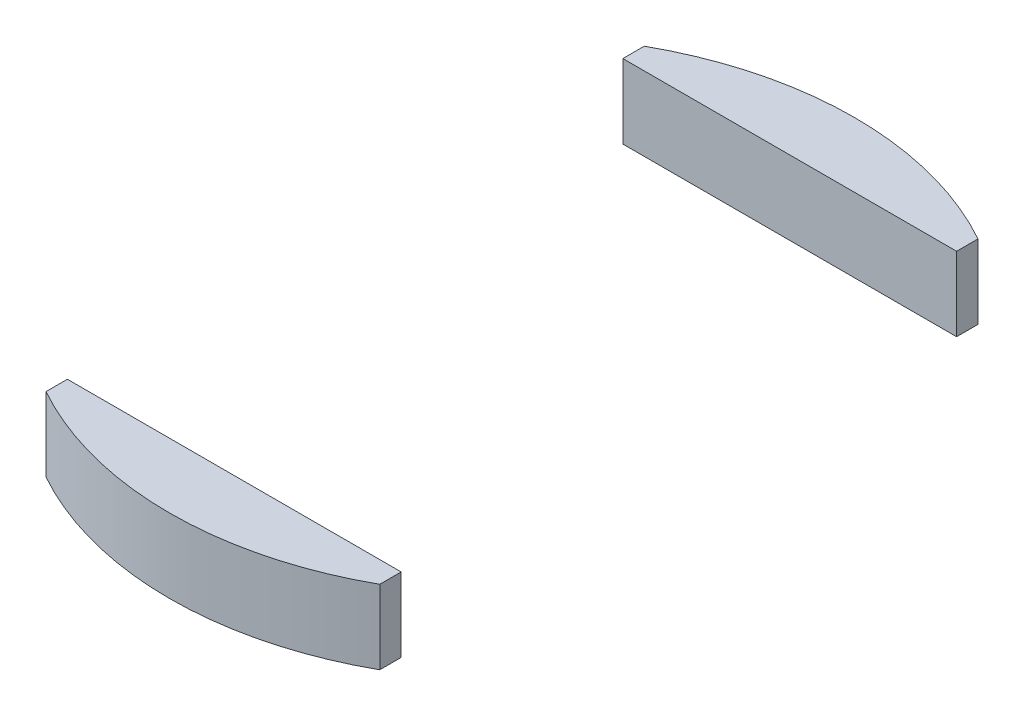
from build123d import *

# Parameters (mm, degrees)
BOSS_EXTRUDE1_DEPTH = 4


with BuildPart() as part:
    # Sketch1 → Boss-Extrude1 (new body)
    with BuildSketch(Plane(origin=(0, 0, 0), x_dir=(1, 0, 0), z_dir=(0, 1, 0))):
        with BuildLine():
            ThreePointArc((9.013878189, 15), (0, 17.5), (-9.013878189, 15))
            Line((-9.013878189, 15), (9.013878189, 15))
        make_face()
        with BuildLine():
            Line((-9.013878189, 16.155494421), (-9.013878189, 15))
            ThreePointArc((-9.013878189, 15), (0, 17.5), (9.013878189, 15))
            Line((9.013878189, 15), (9.013878189, 16.155494421))
            ThreePointArc((9.013878189, 16.155494421), (0, 18.5), (-9.013878189, 16.155494421))
        make_face()
        with BuildLine():
            Line((9.013878189, -15), (-9.013878189, -15))
            ThreePointArc((-9.013878189, -15), (0, -17.5), (9.013878189, -15))
        make_face()
        with BuildLine():
            ThreePointArc((9.013878189, -15), (0, -17.5), (-9.013878189, -15))
            Line((-9.013878189, -15), (-9.013878189, -16.155494421))
            ThreePointArc((-9.013878189, -16.155494421), (0, -18.5), (9.013878189, -16.155494421))
            Line((9.013878189, -16.155494421), (9.013878189, -15))
        make_face()
    extrude(amount=BOSS_EXTRUDE1_DEPTH)


solid = part.part
